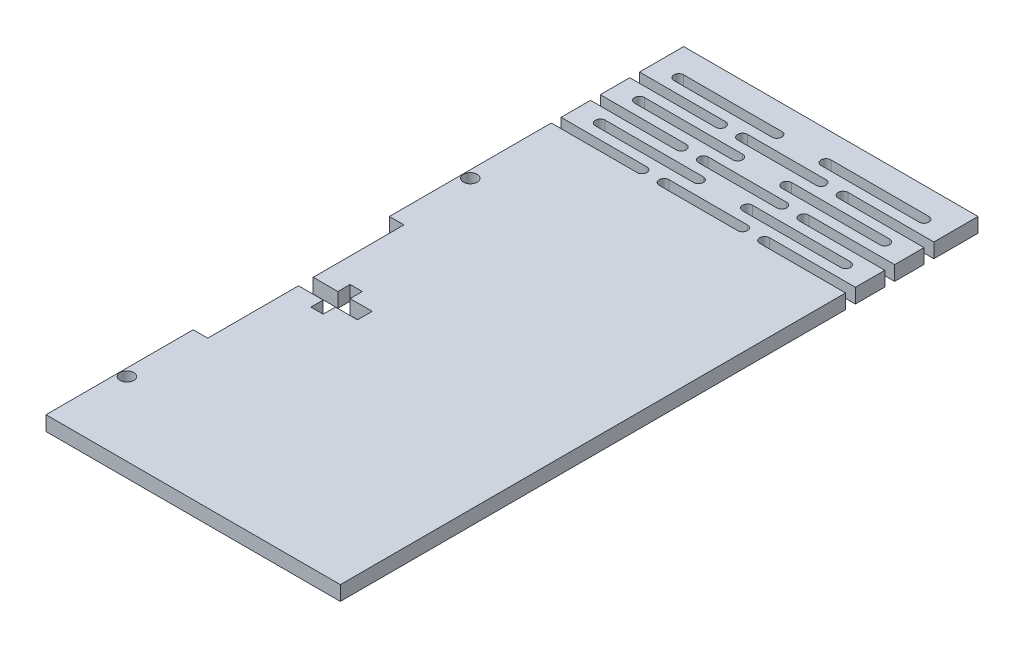
from build123d import *

# Parameters (mm, degrees)
SKETCH_1_W                  = 60
SKETCH_1_H                  = 100
EXTRUDE_1_DEPTH             = 2.9718
SKETCH_2_W                  = 2.9718
SKETCH_2_H                  = 40
CUT_EXTRUDE_1_DEPTH         = 10
SKETCH_4_W                  = 60
SKETCH_4_H                  = 30
EXTRUDE_2_DEPTH             = 2.9718
CUT_EXTRUDE_2_DEPTH         = 2.9718
PATTERN_LINEAR_1_COUNT      = 3
PATTERN_LINEAR_1_PITCH      = 8
SKETCH_5_R                  = 1
CUT_EXTRUDE_3_DEPTH         = 10
PATTERN_LINEAR_2_COUNT      = 3
PATTERN_LINEAR_2_PITCH      = 8
PATTERN_LINEAR_2_COUNT_DIR2 = 2
PATTERN_LINEAR_2_PITCH_DIR2 = 30
CUT_EXTRUDE_4_DEPTH         = 10
SKETCH_8_R                  = 1.4
CUT_EXTRUDE_5_DEPTH         = 10
PATTERN_LINEAR_3_COUNT      = 4
PATTERN_LINEAR_3_PITCH      = 70


with BuildPart() as part:
    # 草图1 → 凸台-拉伸1 (new body)
    with BuildSketch(Plane(origin=(0, 0, 0), x_dir=(1, 0, 0), z_dir=(0, 1, 0))):
        Rectangle(SKETCH_1_W, SKETCH_1_H)
    extrude(amount=EXTRUDE_1_DEPTH)

    # 草图2 → 切除-拉伸1 (cut)
    with BuildSketch(Plane(origin=(0, 0, 0), x_dir=(-1, 0, 0), z_dir=(0, -1, 0))):
        with Locations((28.5141, 0)):
            Rectangle(SKETCH_2_W, SKETCH_2_H)
    extrude(amount=-CUT_EXTRUDE_1_DEPTH, mode=Mode.SUBTRACT)

    # 草图4 → 凸台-拉伸2 (add)
    with BuildSketch(Plane.XZ):
        with Locations((0, -65)):
            Rectangle(SKETCH_4_W, SKETCH_4_H)
    extrude(amount=-EXTRUDE_2_DEPTH)

    # 草图3 → 切除-拉伸2 (cut)
    with BuildSketch(Plane(origin=(0, 0, 0), x_dir=(-1, 0, 0), z_dir=(0, -1, 0))):
        with BuildLine():
            Line((-12.5, 55.002516758), (-30, 55.002516758))
            Line((-30, 55.002516758), (-30, 53.002516758))
            Line((-30, 53.002516758), (-12.5, 53.002516758))
            ThreePointArc((-12.5, 53.002516758), (-11.5, 54.002516758), (-12.5, 55.002516758))
        make_face()
        with BuildLine():
            Line((30, 53.002516758), (30, 55.002516758))
            Line((30, 55.002516758), (12.5, 55.002516758))
            ThreePointArc((12.5, 55.002516758), (11.5, 54.002516758), (12.5, 53.002516758))
            Line((12.5, 53.002516758), (30, 53.002516758))
        make_face()
        with BuildLine():
            Line((8, 55.002516758), (-8, 55.002516758))
            ThreePointArc((-8, 55.002516758), (-9, 54.002516758), (-8, 53.002516758))
            Line((-8, 53.002516758), (8, 53.002516758))
            ThreePointArc((8, 53.002516758), (9, 54.002516758), (8, 55.002516758))
        make_face()
    cut_extrude_2 = extrude(amount=-CUT_EXTRUDE_2_DEPTH, mode=Mode.SUBTRACT)

    # 阵列(线性)1: 切除-拉伸2 ×3
    with Locations(*[(0, 0, -i * PATTERN_LINEAR_1_PITCH) for i in range(1, PATTERN_LINEAR_1_COUNT)]):
        add(cut_extrude_2, mode=Mode.SUBTRACT)

    # 草图5 → 切除-拉伸3 (cut)
    with BuildSketch(Plane.XZ):
        with BuildLine():
            Line((-5, -57.002516758), (-25, -57.002516758))
            ThreePointArc((-25, -57.002516758), (-24.292893219, -57.295409977), (-24, -58.002516758))
            ThreePointArc((-24, -58.002516758), (-24.292893219, -58.709623539), (-25, -59.002516758))
            Line((-25, -59.002516758), (-5, -59.002516758))
            ThreePointArc((-5, -59.002516758), (-6, -58.002516758), (-5, -57.002516758))
        make_face()
        with Locations((-25, -58.002516758)):
            Circle(SKETCH_5_R)
        with Locations((-5, -58.002516758)):
            Circle(SKETCH_5_R)
    cut_extrude_3 = extrude(amount=-CUT_EXTRUDE_3_DEPTH, mode=Mode.SUBTRACT)

    # 阵列(线性)2: Cut-Extrude 3 3 × 2
    with Locations(*[(j * PATTERN_LINEAR_2_PITCH_DIR2, 0, -i * PATTERN_LINEAR_2_PITCH) for i in range(PATTERN_LINEAR_2_COUNT) for j in range(PATTERN_LINEAR_2_COUNT_DIR2) if (i, j) != (0, 0)]):
        add(cut_extrude_3, mode=Mode.SUBTRACT)

    # 草图7 → 切除-拉伸4 (cut)
    with BuildSketch(Plane.XZ):
        Polygon((-30, 1.5), (-30, 0), (-15, 0), (-15, 1.5), (-19.5, 1.5), (-19.5, 4), (-22, 4), (-22, 1.5), align=None)
        Polygon((-30, 0), (-30, -1.5), (-22, -1.5), (-22, -4), (-19.5, -4), (-19.5, -1.5), (-15, -1.5), (-15, 0), align=None)
    extrude(amount=-CUT_EXTRUDE_4_DEPTH, mode=Mode.SUBTRACT)

    # 草图8 → 切除-拉伸5 (cut)
    with BuildSketch(Plane(origin=(0, 0, 0), x_dir=(-1, 0, 0), z_dir=(0, -1, 0))):
        with Locations((28.5, -35)):
            Circle(SKETCH_8_R)
    cut_extrude_5 = extrude(amount=-CUT_EXTRUDE_5_DEPTH, mode=Mode.SUBTRACT)

    # 阵列(线性)3: 切除-拉伸5 ×4
    with Locations(*[(0, 0, -i * PATTERN_LINEAR_3_PITCH) for i in range(1, PATTERN_LINEAR_3_COUNT)]):
        add(cut_extrude_5, mode=Mode.SUBTRACT)


solid = part.part
